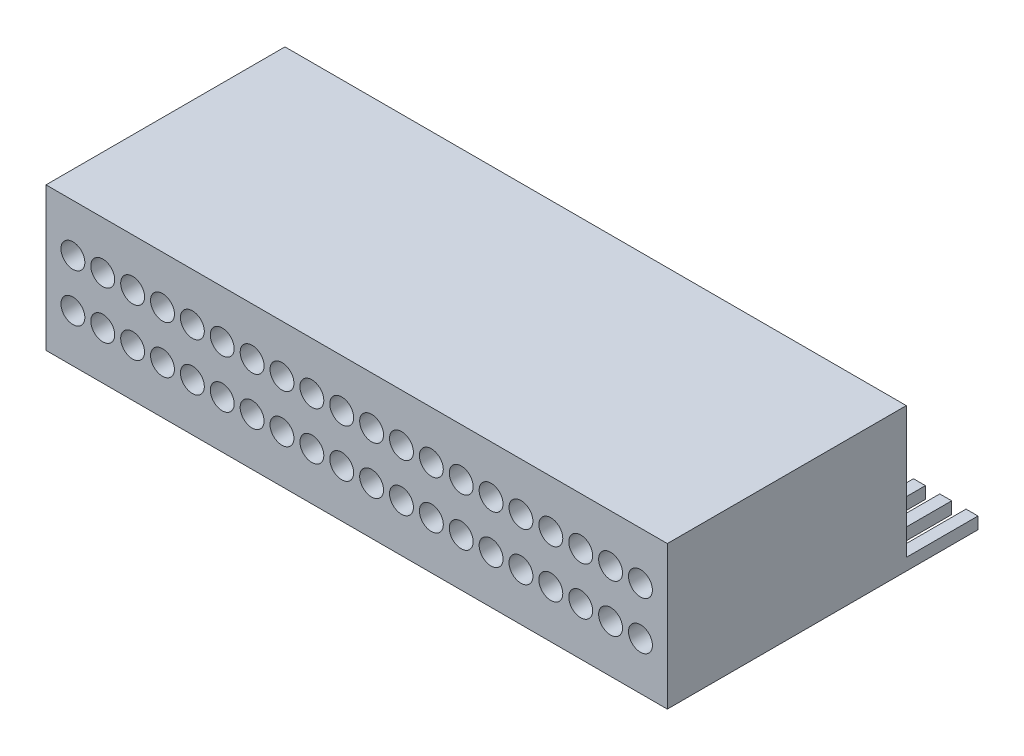
from build123d import *

# Parameters (mm, degrees)
SKETCH2_W           = 26
SKETCH2_H           = 6
BOSS_EXTRUDE1_DEPTH = 10
SKETCH3_R           = 0.5
CUT_EXTRUDE1_DEPTH  = 5
SKETCH4_W           = 0.5
SKETCH4_H           = 3
BOSS_EXTRUDE2_DEPTH = 0.5


with BuildPart() as part:
    # Sketch2 → Boss-Extrude1 (new body)
    with BuildSketch(Plane.XY):
        with Locations((13, 3)):
            Rectangle(SKETCH2_W, SKETCH2_H)
    extrude(amount=BOSS_EXTRUDE1_DEPTH)

    # Sketch3 → Cut-Extrude1 (cut)
    with BuildSketch(Plane.XY.offset(10)):
        with Locations((1.125, 2)):
            Circle(SKETCH3_R)
        with Locations((2.375, 2)):
            Circle(SKETCH3_R)
        with Locations((3.625, 2)):
            Circle(SKETCH3_R)
        with Locations((4.875, 2)):
            Circle(SKETCH3_R)
        with Locations((6.125, 2)):
            Circle(SKETCH3_R)
        with Locations((7.375, 2)):
            Circle(SKETCH3_R)
        with Locations((8.625, 2)):
            Circle(SKETCH3_R)
        with Locations((9.875, 2)):
            Circle(SKETCH3_R)
        with Locations((11.125, 2)):
            Circle(SKETCH3_R)
        with Locations((12.375, 2)):
            Circle(SKETCH3_R)
        with Locations((13.625, 2)):
            Circle(SKETCH3_R)
        with Locations((14.875, 2)):
            Circle(SKETCH3_R)
        with Locations((16.125, 2)):
            Circle(SKETCH3_R)
        with Locations((17.375, 2)):
            Circle(SKETCH3_R)
        with Locations((18.625, 2)):
            Circle(SKETCH3_R)
        with Locations((19.875, 2)):
            Circle(SKETCH3_R)
        with Locations((21.125, 2)):
            Circle(SKETCH3_R)
        with Locations((22.375, 2)):
            Circle(SKETCH3_R)
        with Locations((23.625, 2)):
            Circle(SKETCH3_R)
        with Locations((24.875, 2)):
            Circle(SKETCH3_R)
    cut_extrude1 = extrude(amount=-CUT_EXTRUDE1_DEPTH, mode=Mode.SUBTRACT)

    # Sketch4 → Boss-Extrude2 (add)
    with BuildSketch(Plane(origin=(0, 0, 0), x_dir=(-1, 0, 0), z_dir=(0, -1, 0))):
        with Locations((-24.65, 1.5)):
            Rectangle(SKETCH4_W, SKETCH4_H)
        with Locations((-25.75, 1.5)):
            Rectangle(SKETCH4_W, SKETCH4_H)
        with Locations((-23.55, 1.5)):
            Rectangle(SKETCH4_W, SKETCH4_H)
        with Locations((-22.45, 1.5)):
            Rectangle(SKETCH4_W, SKETCH4_H)
        with Locations((-21.35, 1.5)):
            Rectangle(SKETCH4_W, SKETCH4_H)
        with Locations((-20.25, 1.5)):
            Rectangle(SKETCH4_W, SKETCH4_H)
        with Locations((-19.15, 1.5)):
            Rectangle(SKETCH4_W, SKETCH4_H)
        with Locations((-18.05, 1.5)):
            Rectangle(SKETCH4_W, SKETCH4_H)
        with Locations((-16.95, 1.5)):
            Rectangle(SKETCH4_W, SKETCH4_H)
        with Locations((-15.85, 1.5)):
            Rectangle(SKETCH4_W, SKETCH4_H)
        with Locations((-14.75, 1.5)):
            Rectangle(SKETCH4_W, SKETCH4_H)
        with Locations((-13.65, 1.5)):
            Rectangle(SKETCH4_W, SKETCH4_H)
        with Locations((-12.55, 1.5)):
            Rectangle(SKETCH4_W, SKETCH4_H)
        with Locations((-11.45, 1.5)):
            Rectangle(SKETCH4_W, SKETCH4_H)
        with Locations((-10.35, 1.5)):
            Rectangle(SKETCH4_W, SKETCH4_H)
        with Locations((-9.25, 1.5)):
            Rectangle(SKETCH4_W, SKETCH4_H)
        with Locations((-8.15, 1.5)):
            Rectangle(SKETCH4_W, SKETCH4_H)
        with Locations((-7.05, 1.5)):
            Rectangle(SKETCH4_W, SKETCH4_H)
        with Locations((-5.95, 1.5)):
            Rectangle(SKETCH4_W, SKETCH4_H)
        with Locations((-4.85, 1.5)):
            Rectangle(SKETCH4_W, SKETCH4_H)
        with Locations((-3.75, 1.5)):
            Rectangle(SKETCH4_W, SKETCH4_H)
        with Locations((-2.65, 1.5)):
            Rectangle(SKETCH4_W, SKETCH4_H)
        with Locations((-1.55, 1.5)):
            Rectangle(SKETCH4_W, SKETCH4_H)
        with Locations((-0.45, 1.5)):
            Rectangle(SKETCH4_W, SKETCH4_H)
    extrude(amount=-BOSS_EXTRUDE2_DEPTH)

    # Mirror1: Cut-Extrude1 across plane
    add(cut_extrude1.mirror(Plane(origin=(0, 3, 0), x_dir=(0, 0, 1), z_dir=(0, -1, 0))), mode=Mode.SUBTRACT)


solid = part.part
